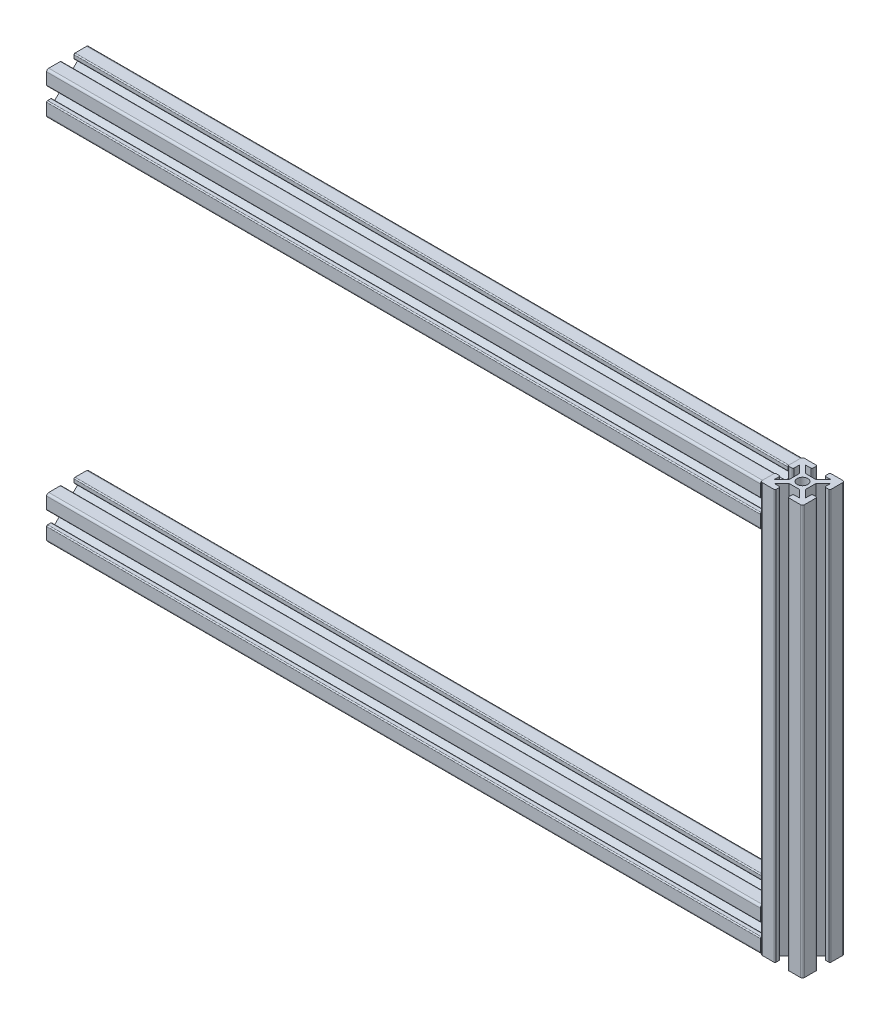
from build123d import *

# Parameters (mm, degrees)
SKETCH1_R                               = 2.5
ALUMINIUM_PROF_ALUMINIUM_PROF_1_DEPTH   = 365.192388155
SKETCH1_ON_SEGMENT_2_R                  = 2.5
ALUMINIUM_PROF_ALUMINIUM_PROF_1_2_DEPTH = 205.384776311
SKETCH1_ON_SEGMENT_3_R                  = 2.5
ALUMINIUM_PROF_ALUMINIUM_PROF_1_3_DEPTH = 365.192388155
BODY_START                              = 61.926406871
BODY_2_RUN_ON_DEPTH                     = 57.269552622
BODY_START_2                            = 143.458369439
BODY_2_RUN_ON_2_DEPTH                   = 57.269552622
SKETCH3_R                               = 2.5
CUT_EXTRUDE1_DEPTH                      = 10


with BuildPart() as part:
    # Sketch1 → Aluminium prof ALUMINIUM PROF(1) (new body)
    with BuildSketch(Plane.YZ):
        with BuildLine():
            Line((-2.5, 4), (2.5, 4))
            Line((2.5, 4), (6.035533906, 7.535533906))
            Line((6.035533906, 7.535533906), (3.535533906, 7.535533906))
            ThreePointArc((3.535533906, 7.535533906), (3.181980515, 7.681980515), (3.035533906, 8.035533906))
            Line((3.035533906, 8.035533906), (3.035533906, 9.535533906))
            ThreePointArc((3.035533906, 9.535533906), (3.181980515, 9.889087297), (3.535533906, 10.035533906))
            Line((3.535533906, 10.035533906), (9.035533906, 10.035533906))
            ThreePointArc((9.035533906, 10.035533906), (9.742640687, 9.742640687), (10.035533906, 9.035533906))
            Line((10.035533906, 9.035533906), (10.035533906, 3.535533906))
            ThreePointArc((10.035533906, 3.535533906), (9.889087297, 3.181980515), (9.535533906, 3.035533906))
            Line((9.535533906, 3.035533906), (8.035533906, 3.035533906))
            ThreePointArc((8.035533906, 3.035533906), (7.681980515, 3.181980515), (7.535533906, 3.535533906))
            Line((7.535533906, 3.535533906), (7.535533906, 6.035533906))
            Line((7.535533906, 6.035533906), (4, 2.5))
            Line((4, 2.5), (4, -2.5))
            Line((4, -2.5), (7.535533906, -6.035533906))
            Line((7.535533906, -6.035533906), (7.535533906, -3.535533906))
            ThreePointArc((7.535533906, -3.535533906), (7.681980515, -3.181980515), (8.035533906, -3.035533906))
            Line((8.035533906, -3.035533906), (9.535533906, -3.035533906))
            ThreePointArc((9.535533906, -3.035533906), (9.889087297, -3.181980515), (10.035533906, -3.535533906))
            Line((10.035533906, -3.535533906), (10.035533906, -9.035533906))
            ThreePointArc((10.035533906, -9.035533906), (9.742640687, -9.742640687), (9.035533906, -10.035533906))
            Line((9.035533906, -10.035533906), (3.535533906, -10.035533906))
            ThreePointArc((3.535533906, -10.035533906), (3.181980515, -9.889087297), (3.035533906, -9.535533906))
            Line((3.035533906, -9.535533906), (3.035533906, -8.035533906))
            ThreePointArc((3.035533906, -8.035533906), (3.181980515, -7.681980515), (3.535533906, -7.535533906))
            Line((3.535533906, -7.535533906), (6.035533906, -7.535533906))
            Line((6.035533906, -7.535533906), (2.5, -4))
            Line((2.5, -4), (-2.5, -4))
            Line((-2.5, -4), (-6.035533906, -7.535533906))
            Line((-6.035533906, -7.535533906), (-3.535533906, -7.535533906))
            ThreePointArc((-3.535533906, -7.535533906), (-3.181980515, -7.681980515), (-3.035533906, -8.035533906))
            Line((-3.035533906, -8.035533906), (-3.035533906, -9.535533906))
            ThreePointArc((-3.035533906, -9.535533906), (-3.181980515, -9.889087297), (-3.535533906, -10.035533906))
            Line((-3.535533906, -10.035533906), (-9.035533906, -10.035533906))
            ThreePointArc((-9.035533906, -10.035533906), (-9.742640687, -9.742640687), (-10.035533906, -9.035533906))
            Line((-10.035533906, -9.035533906), (-10.035533906, -3.535533906))
            ThreePointArc((-10.035533906, -3.535533906), (-9.889087297, -3.181980515), (-9.535533906, -3.035533906))
            Line((-9.535533906, -3.035533906), (-8.035533906, -3.035533906))
            ThreePointArc((-8.035533906, -3.035533906), (-7.681980515, -3.181980515), (-7.535533906, -3.535533906))
            Line((-7.535533906, -3.535533906), (-7.535533906, -6.035533906))
            Line((-7.535533906, -6.035533906), (-4, -2.5))
            Line((-4, -2.5), (-4, 2.5))
            Line((-4, 2.5), (-7.535533906, 6.035533906))
            Line((-7.535533906, 6.035533906), (-7.535533906, 3.535533906))
            ThreePointArc((-7.535533906, 3.535533906), (-7.681980515, 3.181980515), (-8.035533906, 3.035533906))
            Line((-8.035533906, 3.035533906), (-9.535533906, 3.035533906))
            ThreePointArc((-9.535533906, 3.035533906), (-9.889087297, 3.181980515), (-10.035533906, 3.535533906))
            Line((-10.035533906, 3.535533906), (-10.035533906, 9.035533906))
            ThreePointArc((-10.035533906, 9.035533906), (-9.742640687, 9.742640687), (-9.035533906, 10.035533906))
            Line((-9.035533906, 10.035533906), (-3.535533906, 10.035533906))
            ThreePointArc((-3.535533906, 10.035533906), (-3.181980515, 9.889087297), (-3.035533906, 9.535533906))
            Line((-3.035533906, 9.535533906), (-3.035533906, 8.035533906))
            ThreePointArc((-3.035533906, 8.035533906), (-3.181980515, 7.681980515), (-3.535533906, 7.535533906))
            Line((-3.535533906, 7.535533906), (-6.035533906, 7.535533906))
            Line((-6.035533906, 7.535533906), (-2.5, 4))
        make_face()
        Circle(SKETCH1_R, mode=Mode.SUBTRACT)
    extrude(amount=ALUMINIUM_PROF_ALUMINIUM_PROF_1_DEPTH)

    # Aluminium prof ALUMINIUM PROF(1) mitre 1
    split(bisect_by=Plane(origin=(350, 0, 0), x_dir=(-0.707106781, -0.707106781, 0), z_dir=(-0.707106781, 0.707106781, 0)), keep=Keep.TOP)

    # Trim_Extend1 8
    split(bisect_by=Plane(origin=(355.778935513, -87.5, 4.278935513), x_dir=(0, -1, 0), z_dir=(-0.707106781, 0, 0.707106781)), keep=Keep.TOP)

    # Trim_Extend1 10
    split(bisect_by=Plane(origin=(355.778935513, -87.5, -4.278935513), x_dir=(0, -1, 0), z_dir=(-0.707106781, 0, -0.707106781)), keep=Keep.TOP)

    # Trim_Extend1 21
    split(bisect_by=Plane(origin=(339.964466094, -87.5, 6.285533906), x_dir=(0, -1, 0), z_dir=(-1, 0, 0)), keep=Keep.TOP)

    # Sketch3 → Cut-Extrude1 (cut)
    with BuildSketch(Plane(origin=(0, 4, 0), x_dir=(1, 0, 0), z_dir=(0, 1, 0))):
        with Locations(Location((75, 0, 0), (0, 0, 270))):
            Circle(SKETCH3_R)
        with Locations(Location((175, 0, 0), (0, 0, 270))):
            Circle(SKETCH3_R)
        with Locations(Location((264.964466094, 0, 0), (0, 0, 270))):
            Circle(SKETCH3_R)
    extrude(amount=-CUT_EXTRUDE1_DEPTH, mode=Mode.SUBTRACT)


with BuildPart() as body_2:
    # Sketch1 on segment 2 (carried to segment 2) → Aluminium prof ALUMINIUM PROF_1 2 (new body)
    with BuildSketch(Plane(origin=(350, 15.192388155, 0), x_dir=(1, 0, 0), z_dir=(0, -1, 0))):
        with BuildLine():
            Line((-2.5, 4), (2.5, 4))
            Line((2.5, 4), (6.035533906, 7.535533906))
            Line((6.035533906, 7.535533906), (3.535533906, 7.535533906))
            ThreePointArc((3.535533906, 7.535533906), (3.181980515, 7.681980515), (3.035533906, 8.035533906))
            Line((3.035533906, 8.035533906), (3.035533906, 9.535533906))
            ThreePointArc((3.035533906, 9.535533906), (3.181980515, 9.889087297), (3.535533906, 10.035533906))
            Line((3.535533906, 10.035533906), (9.035533906, 10.035533906))
            ThreePointArc((9.035533906, 10.035533906), (9.742640687, 9.742640687), (10.035533906, 9.035533906))
            Line((10.035533906, 9.035533906), (10.035533906, 3.535533906))
            ThreePointArc((10.035533906, 3.535533906), (9.889087297, 3.181980515), (9.535533906, 3.035533906))
            Line((9.535533906, 3.035533906), (8.035533906, 3.035533906))
            ThreePointArc((8.035533906, 3.035533906), (7.681980515, 3.181980515), (7.535533906, 3.535533906))
            Line((7.535533906, 3.535533906), (7.535533906, 6.035533906))
            Line((7.535533906, 6.035533906), (4, 2.5))
            Line((4, 2.5), (4, -2.5))
            Line((4, -2.5), (7.535533906, -6.035533906))
            Line((7.535533906, -6.035533906), (7.535533906, -3.535533906))
            ThreePointArc((7.535533906, -3.535533906), (7.681980515, -3.181980515), (8.035533906, -3.035533906))
            Line((8.035533906, -3.035533906), (9.535533906, -3.035533906))
            ThreePointArc((9.535533906, -3.035533906), (9.889087297, -3.181980515), (10.035533906, -3.535533906))
            Line((10.035533906, -3.535533906), (10.035533906, -9.035533906))
            ThreePointArc((10.035533906, -9.035533906), (9.742640687, -9.742640687), (9.035533906, -10.035533906))
            Line((9.035533906, -10.035533906), (3.535533906, -10.035533906))
            ThreePointArc((3.535533906, -10.035533906), (3.181980515, -9.889087297), (3.035533906, -9.535533906))
            Line((3.035533906, -9.535533906), (3.035533906, -8.035533906))
            ThreePointArc((3.035533906, -8.035533906), (3.181980515, -7.681980515), (3.535533906, -7.535533906))
            Line((3.535533906, -7.535533906), (6.035533906, -7.535533906))
            Line((6.035533906, -7.535533906), (2.5, -4))
            Line((2.5, -4), (-2.5, -4))
            Line((-2.5, -4), (-6.035533906, -7.535533906))
            Line((-6.035533906, -7.535533906), (-3.535533906, -7.535533906))
            ThreePointArc((-3.535533906, -7.535533906), (-3.181980515, -7.681980515), (-3.035533906, -8.035533906))
            Line((-3.035533906, -8.035533906), (-3.035533906, -9.535533906))
            ThreePointArc((-3.035533906, -9.535533906), (-3.181980515, -9.889087297), (-3.535533906, -10.035533906))
            Line((-3.535533906, -10.035533906), (-9.035533906, -10.035533906))
            ThreePointArc((-9.035533906, -10.035533906), (-9.742640687, -9.742640687), (-10.035533906, -9.035533906))
            Line((-10.035533906, -9.035533906), (-10.035533906, -3.535533906))
            ThreePointArc((-10.035533906, -3.535533906), (-9.889087297, -3.181980515), (-9.535533906, -3.035533906))
            Line((-9.535533906, -3.035533906), (-8.035533906, -3.035533906))
            ThreePointArc((-8.035533906, -3.035533906), (-7.681980515, -3.181980515), (-7.535533906, -3.535533906))
            Line((-7.535533906, -3.535533906), (-7.535533906, -6.035533906))
            Line((-7.535533906, -6.035533906), (-4, -2.5))
            Line((-4, -2.5), (-4, 2.5))
            Line((-4, 2.5), (-7.535533906, 6.035533906))
            Line((-7.535533906, 6.035533906), (-7.535533906, 3.535533906))
            ThreePointArc((-7.535533906, 3.535533906), (-7.681980515, 3.181980515), (-8.035533906, 3.035533906))
            Line((-8.035533906, 3.035533906), (-9.535533906, 3.035533906))
            ThreePointArc((-9.535533906, 3.035533906), (-9.889087297, 3.181980515), (-10.035533906, 3.535533906))
            Line((-10.035533906, 3.535533906), (-10.035533906, 9.035533906))
            ThreePointArc((-10.035533906, 9.035533906), (-9.742640687, 9.742640687), (-9.035533906, 10.035533906))
            Line((-9.035533906, 10.035533906), (-3.535533906, 10.035533906))
            ThreePointArc((-3.535533906, 10.035533906), (-3.181980515, 9.889087297), (-3.035533906, 9.535533906))
            Line((-3.035533906, 9.535533906), (-3.035533906, 8.035533906))
            ThreePointArc((-3.035533906, 8.035533906), (-3.181980515, 7.681980515), (-3.535533906, 7.535533906))
            Line((-3.535533906, 7.535533906), (-6.035533906, 7.535533906))
            Line((-6.035533906, 7.535533906), (-2.5, 4))
        make_face()
        Circle(SKETCH1_ON_SEGMENT_2_R, mode=Mode.SUBTRACT)
    extrude(amount=ALUMINIUM_PROF_ALUMINIUM_PROF_1_2_DEPTH)

    # Aluminium prof ALUMINIUM PROF_1 2 mitre
    split(bisect_by=Plane(origin=(350, 0, 0), x_dir=(0.707106781, 0.707106781, 0), z_dir=(0.707106781, -0.707106781, 0)), keep=Keep.TOP)

    # Aluminium prof ALUMINIUM PROF_1 2 mi 2
    split(bisect_by=Plane(origin=(350, -175, 0), x_dir=(-0.707106781, 0.707106781, 0), z_dir=(0.707106781, 0.707106781, 0)), keep=Keep.TOP)

    # body 2 cut square before the run-on
    split(bisect_by=Plane(origin=(350, -46.734018716, 0), x_dir=(1, 0, 0), z_dir=(0, -1, 0)), keep=Keep.TOP)

    # Sketch1 on segment 2 (carried to segment 2) → body 2 run on (add)
    with BuildSketch(Plane(origin=(350, 15.192388155, 0), x_dir=(1, 0, 0), z_dir=(0, -1, 0)).offset(BODY_START)):
        with BuildLine():
            Line((-2.5, 4), (2.5, 4))
            Line((2.5, 4), (6.035533906, 7.535533906))
            Line((6.035533906, 7.535533906), (3.535533906, 7.535533906))
            ThreePointArc((3.535533906, 7.535533906), (3.181980515, 7.681980515), (3.035533906, 8.035533906))
            Line((3.035533906, 8.035533906), (3.035533906, 9.535533906))
            ThreePointArc((3.035533906, 9.535533906), (3.181980515, 9.889087297), (3.535533906, 10.035533906))
            Line((3.535533906, 10.035533906), (9.035533906, 10.035533906))
            ThreePointArc((9.035533906, 10.035533906), (9.742640687, 9.742640687), (10.035533906, 9.035533906))
            Line((10.035533906, 9.035533906), (10.035533906, 3.535533906))
            ThreePointArc((10.035533906, 3.535533906), (9.889087297, 3.181980515), (9.535533906, 3.035533906))
            Line((9.535533906, 3.035533906), (8.035533906, 3.035533906))
            ThreePointArc((8.035533906, 3.035533906), (7.681980515, 3.181980515), (7.535533906, 3.535533906))
            Line((7.535533906, 3.535533906), (7.535533906, 6.035533906))
            Line((7.535533906, 6.035533906), (4, 2.5))
            Line((4, 2.5), (4, -2.5))
            Line((4, -2.5), (7.535533906, -6.035533906))
            Line((7.535533906, -6.035533906), (7.535533906, -3.535533906))
            ThreePointArc((7.535533906, -3.535533906), (7.681980515, -3.181980515), (8.035533906, -3.035533906))
            Line((8.035533906, -3.035533906), (9.535533906, -3.035533906))
            ThreePointArc((9.535533906, -3.035533906), (9.889087297, -3.181980515), (10.035533906, -3.535533906))
            Line((10.035533906, -3.535533906), (10.035533906, -9.035533906))
            ThreePointArc((10.035533906, -9.035533906), (9.742640687, -9.742640687), (9.035533906, -10.035533906))
            Line((9.035533906, -10.035533906), (3.535533906, -10.035533906))
            ThreePointArc((3.535533906, -10.035533906), (3.181980515, -9.889087297), (3.035533906, -9.535533906))
            Line((3.035533906, -9.535533906), (3.035533906, -8.035533906))
            ThreePointArc((3.035533906, -8.035533906), (3.181980515, -7.681980515), (3.535533906, -7.535533906))
            Line((3.535533906, -7.535533906), (6.035533906, -7.535533906))
            Line((6.035533906, -7.535533906), (2.5, -4))
            Line((2.5, -4), (-2.5, -4))
            Line((-2.5, -4), (-6.035533906, -7.535533906))
            Line((-6.035533906, -7.535533906), (-3.535533906, -7.535533906))
            ThreePointArc((-3.535533906, -7.535533906), (-3.181980515, -7.681980515), (-3.035533906, -8.035533906))
            Line((-3.035533906, -8.035533906), (-3.035533906, -9.535533906))
            ThreePointArc((-3.035533906, -9.535533906), (-3.181980515, -9.889087297), (-3.535533906, -10.035533906))
            Line((-3.535533906, -10.035533906), (-9.035533906, -10.035533906))
            ThreePointArc((-9.035533906, -10.035533906), (-9.742640687, -9.742640687), (-10.035533906, -9.035533906))
            Line((-10.035533906, -9.035533906), (-10.035533906, -3.535533906))
            ThreePointArc((-10.035533906, -3.535533906), (-9.889087297, -3.181980515), (-9.535533906, -3.035533906))
            Line((-9.535533906, -3.035533906), (-8.035533906, -3.035533906))
            ThreePointArc((-8.035533906, -3.035533906), (-7.681980515, -3.181980515), (-7.535533906, -3.535533906))
            Line((-7.535533906, -3.535533906), (-7.535533906, -6.035533906))
            Line((-7.535533906, -6.035533906), (-4, -2.5))
            Line((-4, -2.5), (-4, 2.5))
            Line((-4, 2.5), (-7.535533906, 6.035533906))
            Line((-7.535533906, 6.035533906), (-7.535533906, 3.535533906))
            ThreePointArc((-7.535533906, 3.535533906), (-7.681980515, 3.181980515), (-8.035533906, 3.035533906))
            Line((-8.035533906, 3.035533906), (-9.535533906, 3.035533906))
            ThreePointArc((-9.535533906, 3.035533906), (-9.889087297, 3.181980515), (-10.035533906, 3.535533906))
            Line((-10.035533906, 3.535533906), (-10.035533906, 9.035533906))
            ThreePointArc((-10.035533906, 9.035533906), (-9.742640687, 9.742640687), (-9.035533906, 10.035533906))
            Line((-9.035533906, 10.035533906), (-3.535533906, 10.035533906))
            ThreePointArc((-3.535533906, 10.035533906), (-3.181980515, 9.889087297), (-3.035533906, 9.535533906))
            Line((-3.035533906, 9.535533906), (-3.035533906, 8.035533906))
            ThreePointArc((-3.035533906, 8.035533906), (-3.181980515, 7.681980515), (-3.535533906, 7.535533906))
            Line((-3.535533906, 7.535533906), (-6.035533906, 7.535533906))
            Line((-6.035533906, 7.535533906), (-2.5, 4))
        make_face()
        Circle(SKETCH1_ON_SEGMENT_2_R, mode=Mode.SUBTRACT)
    extrude(amount=-BODY_2_RUN_ON_DEPTH)

    # Trim_Extend1 2
    split(bisect_by=Plane(origin=(180.017766953, 10.035533906, 6.285533906), x_dir=(1, 0, 0), z_dir=(0, -1, 0)), keep=Keep.TOP)

    # body 2 cut square before the run-on
    split(bisect_by=Plane(origin=(350, -128.265981284, 0), x_dir=(-1, 0, 0), z_dir=(0, 1, 0)), keep=Keep.TOP)

    # Sketch1 on segment 2 (carried to segment 2) → body 2 run on 2 (add)
    with BuildSketch(Plane(origin=(350, 15.192388155, 0), x_dir=(1, 0, 0), z_dir=(0, -1, 0)).offset(BODY_START_2)):
        with BuildLine():
            Line((-2.5, 4), (2.5, 4))
            Line((2.5, 4), (6.035533906, 7.535533906))
            Line((6.035533906, 7.535533906), (3.535533906, 7.535533906))
            ThreePointArc((3.535533906, 7.535533906), (3.181980515, 7.681980515), (3.035533906, 8.035533906))
            Line((3.035533906, 8.035533906), (3.035533906, 9.535533906))
            ThreePointArc((3.035533906, 9.535533906), (3.181980515, 9.889087297), (3.535533906, 10.035533906))
            Line((3.535533906, 10.035533906), (9.035533906, 10.035533906))
            ThreePointArc((9.035533906, 10.035533906), (9.742640687, 9.742640687), (10.035533906, 9.035533906))
            Line((10.035533906, 9.035533906), (10.035533906, 3.535533906))
            ThreePointArc((10.035533906, 3.535533906), (9.889087297, 3.181980515), (9.535533906, 3.035533906))
            Line((9.535533906, 3.035533906), (8.035533906, 3.035533906))
            ThreePointArc((8.035533906, 3.035533906), (7.681980515, 3.181980515), (7.535533906, 3.535533906))
            Line((7.535533906, 3.535533906), (7.535533906, 6.035533906))
            Line((7.535533906, 6.035533906), (4, 2.5))
            Line((4, 2.5), (4, -2.5))
            Line((4, -2.5), (7.535533906, -6.035533906))
            Line((7.535533906, -6.035533906), (7.535533906, -3.535533906))
            ThreePointArc((7.535533906, -3.535533906), (7.681980515, -3.181980515), (8.035533906, -3.035533906))
            Line((8.035533906, -3.035533906), (9.535533906, -3.035533906))
            ThreePointArc((9.535533906, -3.035533906), (9.889087297, -3.181980515), (10.035533906, -3.535533906))
            Line((10.035533906, -3.535533906), (10.035533906, -9.035533906))
            ThreePointArc((10.035533906, -9.035533906), (9.742640687, -9.742640687), (9.035533906, -10.035533906))
            Line((9.035533906, -10.035533906), (3.535533906, -10.035533906))
            ThreePointArc((3.535533906, -10.035533906), (3.181980515, -9.889087297), (3.035533906, -9.535533906))
            Line((3.035533906, -9.535533906), (3.035533906, -8.035533906))
            ThreePointArc((3.035533906, -8.035533906), (3.181980515, -7.681980515), (3.535533906, -7.535533906))
            Line((3.535533906, -7.535533906), (6.035533906, -7.535533906))
            Line((6.035533906, -7.535533906), (2.5, -4))
            Line((2.5, -4), (-2.5, -4))
            Line((-2.5, -4), (-6.035533906, -7.535533906))
            Line((-6.035533906, -7.535533906), (-3.535533906, -7.535533906))
            ThreePointArc((-3.535533906, -7.535533906), (-3.181980515, -7.681980515), (-3.035533906, -8.035533906))
            Line((-3.035533906, -8.035533906), (-3.035533906, -9.535533906))
            ThreePointArc((-3.035533906, -9.535533906), (-3.181980515, -9.889087297), (-3.535533906, -10.035533906))
            Line((-3.535533906, -10.035533906), (-9.035533906, -10.035533906))
            ThreePointArc((-9.035533906, -10.035533906), (-9.742640687, -9.742640687), (-10.035533906, -9.035533906))
            Line((-10.035533906, -9.035533906), (-10.035533906, -3.535533906))
            ThreePointArc((-10.035533906, -3.535533906), (-9.889087297, -3.181980515), (-9.535533906, -3.035533906))
            Line((-9.535533906, -3.035533906), (-8.035533906, -3.035533906))
            ThreePointArc((-8.035533906, -3.035533906), (-7.681980515, -3.181980515), (-7.535533906, -3.535533906))
            Line((-7.535533906, -3.535533906), (-7.535533906, -6.035533906))
            Line((-7.535533906, -6.035533906), (-4, -2.5))
            Line((-4, -2.5), (-4, 2.5))
            Line((-4, 2.5), (-7.535533906, 6.035533906))
            Line((-7.535533906, 6.035533906), (-7.535533906, 3.535533906))
            ThreePointArc((-7.535533906, 3.535533906), (-7.681980515, 3.181980515), (-8.035533906, 3.035533906))
            Line((-8.035533906, 3.035533906), (-9.535533906, 3.035533906))
            ThreePointArc((-9.535533906, 3.035533906), (-9.889087297, 3.181980515), (-10.035533906, 3.535533906))
            Line((-10.035533906, 3.535533906), (-10.035533906, 9.035533906))
            ThreePointArc((-10.035533906, 9.035533906), (-9.742640687, 9.742640687), (-9.035533906, 10.035533906))
            Line((-9.035533906, 10.035533906), (-3.535533906, 10.035533906))
            ThreePointArc((-3.535533906, 10.035533906), (-3.181980515, 9.889087297), (-3.035533906, 9.535533906))
            Line((-3.035533906, 9.535533906), (-3.035533906, 8.035533906))
            ThreePointArc((-3.035533906, 8.035533906), (-3.181980515, 7.681980515), (-3.535533906, 7.535533906))
            Line((-3.535533906, 7.535533906), (-6.035533906, 7.535533906))
            Line((-6.035533906, 7.535533906), (-2.5, 4))
        make_face()
        Circle(SKETCH1_ON_SEGMENT_2_R, mode=Mode.SUBTRACT)
    extrude(amount=BODY_2_RUN_ON_2_DEPTH)

    # Trim_Extend2 2
    split(bisect_by=Plane(origin=(180.017766953, -185.035533906, 6.285533906), x_dir=(-1, 0, 0), z_dir=(0, 1, 0)), keep=Keep.TOP)


with BuildPart() as body_3:
    # Sketch1 on segment 3 (carried to segment 3) → Aluminium prof ALUMINIUM PROF_1 3 (new body)
    with BuildSketch(Plane(origin=(365.192388155, -175, 0), x_dir=(0, -1, 0), z_dir=(-1, 0, 0))):
        with BuildLine():
            Line((-2.5, 4), (2.5, 4))
            Line((2.5, 4), (6.035533906, 7.535533906))
            Line((6.035533906, 7.535533906), (3.535533906, 7.535533906))
            ThreePointArc((3.535533906, 7.535533906), (3.181980515, 7.681980515), (3.035533906, 8.035533906))
            Line((3.035533906, 8.035533906), (3.035533906, 9.535533906))
            ThreePointArc((3.035533906, 9.535533906), (3.181980515, 9.889087297), (3.535533906, 10.035533906))
            Line((3.535533906, 10.035533906), (9.035533906, 10.035533906))
            ThreePointArc((9.035533906, 10.035533906), (9.742640687, 9.742640687), (10.035533906, 9.035533906))
            Line((10.035533906, 9.035533906), (10.035533906, 3.535533906))
            ThreePointArc((10.035533906, 3.535533906), (9.889087297, 3.181980515), (9.535533906, 3.035533906))
            Line((9.535533906, 3.035533906), (8.035533906, 3.035533906))
            ThreePointArc((8.035533906, 3.035533906), (7.681980515, 3.181980515), (7.535533906, 3.535533906))
            Line((7.535533906, 3.535533906), (7.535533906, 6.035533906))
            Line((7.535533906, 6.035533906), (4, 2.5))
            Line((4, 2.5), (4, -2.5))
            Line((4, -2.5), (7.535533906, -6.035533906))
            Line((7.535533906, -6.035533906), (7.535533906, -3.535533906))
            ThreePointArc((7.535533906, -3.535533906), (7.681980515, -3.181980515), (8.035533906, -3.035533906))
            Line((8.035533906, -3.035533906), (9.535533906, -3.035533906))
            ThreePointArc((9.535533906, -3.035533906), (9.889087297, -3.181980515), (10.035533906, -3.535533906))
            Line((10.035533906, -3.535533906), (10.035533906, -9.035533906))
            ThreePointArc((10.035533906, -9.035533906), (9.742640687, -9.742640687), (9.035533906, -10.035533906))
            Line((9.035533906, -10.035533906), (3.535533906, -10.035533906))
            ThreePointArc((3.535533906, -10.035533906), (3.181980515, -9.889087297), (3.035533906, -9.535533906))
            Line((3.035533906, -9.535533906), (3.035533906, -8.035533906))
            ThreePointArc((3.035533906, -8.035533906), (3.181980515, -7.681980515), (3.535533906, -7.535533906))
            Line((3.535533906, -7.535533906), (6.035533906, -7.535533906))
            Line((6.035533906, -7.535533906), (2.5, -4))
            Line((2.5, -4), (-2.5, -4))
            Line((-2.5, -4), (-6.035533906, -7.535533906))
            Line((-6.035533906, -7.535533906), (-3.535533906, -7.535533906))
            ThreePointArc((-3.535533906, -7.535533906), (-3.181980515, -7.681980515), (-3.035533906, -8.035533906))
            Line((-3.035533906, -8.035533906), (-3.035533906, -9.535533906))
            ThreePointArc((-3.035533906, -9.535533906), (-3.181980515, -9.889087297), (-3.535533906, -10.035533906))
            Line((-3.535533906, -10.035533906), (-9.035533906, -10.035533906))
            ThreePointArc((-9.035533906, -10.035533906), (-9.742640687, -9.742640687), (-10.035533906, -9.035533906))
            Line((-10.035533906, -9.035533906), (-10.035533906, -3.535533906))
            ThreePointArc((-10.035533906, -3.535533906), (-9.889087297, -3.181980515), (-9.535533906, -3.035533906))
            Line((-9.535533906, -3.035533906), (-8.035533906, -3.035533906))
            ThreePointArc((-8.035533906, -3.035533906), (-7.681980515, -3.181980515), (-7.535533906, -3.535533906))
            Line((-7.535533906, -3.535533906), (-7.535533906, -6.035533906))
            Line((-7.535533906, -6.035533906), (-4, -2.5))
            Line((-4, -2.5), (-4, 2.5))
            Line((-4, 2.5), (-7.535533906, 6.035533906))
            Line((-7.535533906, 6.035533906), (-7.535533906, 3.535533906))
            ThreePointArc((-7.535533906, 3.535533906), (-7.681980515, 3.181980515), (-8.035533906, 3.035533906))
            Line((-8.035533906, 3.035533906), (-9.535533906, 3.035533906))
            ThreePointArc((-9.535533906, 3.035533906), (-9.889087297, 3.181980515), (-10.035533906, 3.535533906))
            Line((-10.035533906, 3.535533906), (-10.035533906, 9.035533906))
            ThreePointArc((-10.035533906, 9.035533906), (-9.742640687, 9.742640687), (-9.035533906, 10.035533906))
            Line((-9.035533906, 10.035533906), (-3.535533906, 10.035533906))
            ThreePointArc((-3.535533906, 10.035533906), (-3.181980515, 9.889087297), (-3.035533906, 9.535533906))
            Line((-3.035533906, 9.535533906), (-3.035533906, 8.035533906))
            ThreePointArc((-3.035533906, 8.035533906), (-3.181980515, 7.681980515), (-3.535533906, 7.535533906))
            Line((-3.535533906, 7.535533906), (-6.035533906, 7.535533906))
            Line((-6.035533906, 7.535533906), (-2.5, 4))
        make_face()
        Circle(SKETCH1_ON_SEGMENT_3_R, mode=Mode.SUBTRACT)
    extrude(amount=ALUMINIUM_PROF_ALUMINIUM_PROF_1_3_DEPTH)

    # Aluminium prof ALUMINIUM PROF_1 3 mitre
    split(bisect_by=Plane(origin=(350, -175, 0), x_dir=(0.707106781, -0.707106781, 0), z_dir=(-0.707106781, -0.707106781, 0)), keep=Keep.TOP)

    # Trim_Extend2 7
    split(bisect_by=Plane(origin=(339.964466094, -77.464466094, 6.285533906), x_dir=(0, -1, 0), z_dir=(-1, 0, 0)), keep=Keep.TOP)


solid = Compound([part.part, body_2.part, body_3.part])
